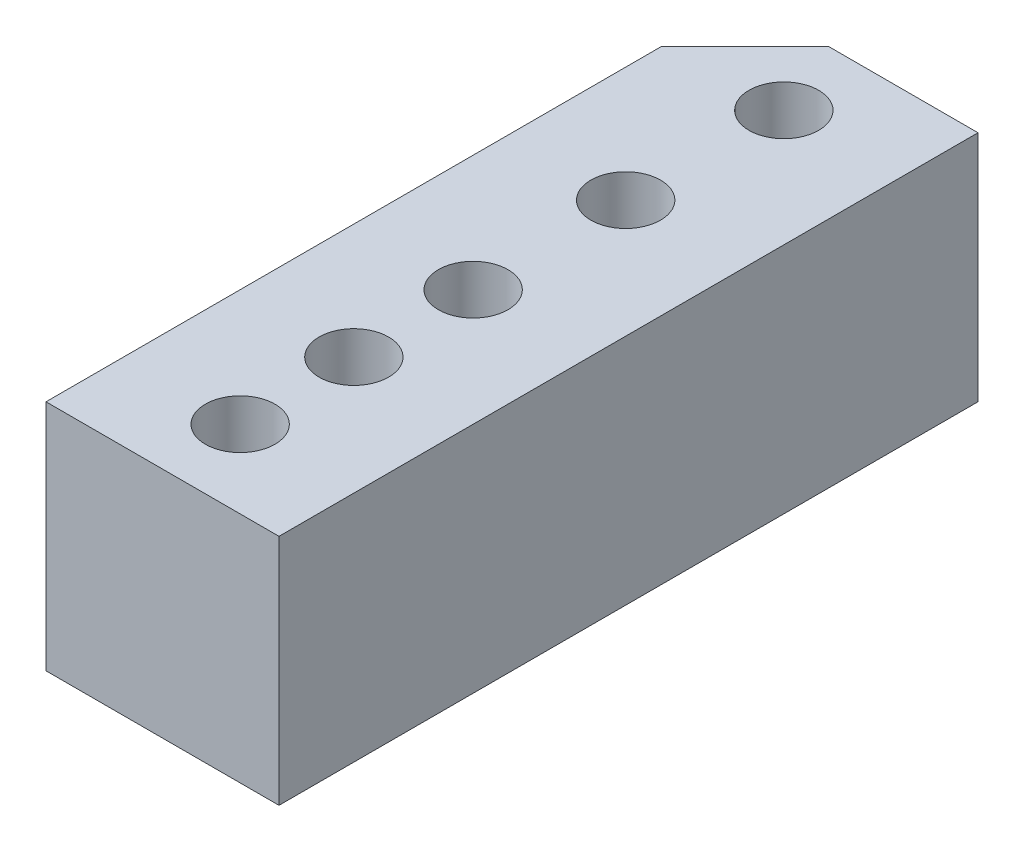
from build123d import *

# Parameters (mm, degrees)
SKETCH1_W             = 9.525
SKETCH1_H             = 9.525
EXTRUDE1_DEPTH        = 28.575
F_4_40_TAPPED_HOLE1_D = 2.8448
F_4_40_TAPPED_HOLE2_D = 2.8448
CHAMFER1_SIZE         = 3.429


with BuildPart() as part:
    # Sketch1 → Extrude1 (new body)
    with BuildSketch(Plane.XY):
        Rectangle(SKETCH1_W, SKETCH1_H)
    extrude(amount=EXTRUDE1_DEPTH)

    # #4-40 Tapped Hole1 (through all)
    with Locations(Plane(origin=(0, 4.7625, 3.175), x_dir=(0, 0, 1), z_dir=(0, 1, 0))):
        with Locations((0, 0), (12.7, 0), (22.225, 0)):
            Hole(F_4_40_TAPPED_HOLE1_D / 2)

    # #4-40 Tapped Hole2 (through all)
    with Locations(Plane(origin=(-0.053117728, -4.7625, 20.699632052), x_dir=(0, 0, -1), z_dir=(0, -1, 0))):
        with Locations((0, 0), (11.1125, 0)):
            Hole(F_4_40_TAPPED_HOLE2_D / 2)

    # Chamfer1
    chamfer1_edges = [part.edges().sort_by_distance(p)[0] for p in [
        (-4.7625, 0, 0),
    ]]
    chamfer(chamfer1_edges, length=CHAMFER1_SIZE)


solid = part.part
